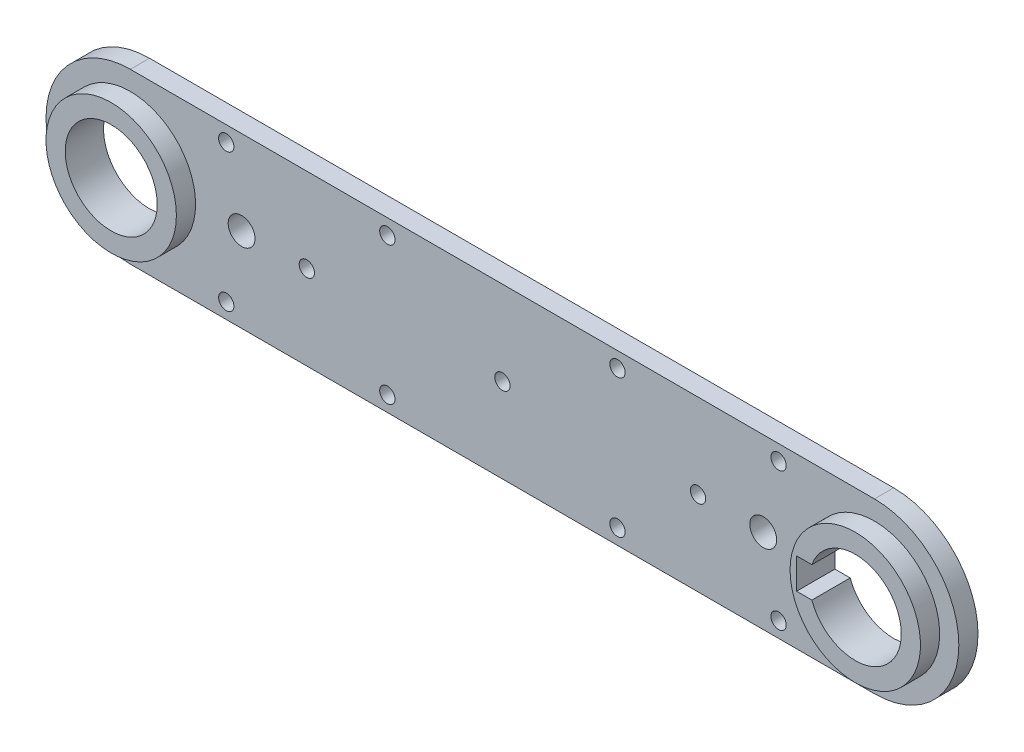
from build123d import *

# Parameters (mm, degrees)
BOSS_EXTRUDE1_DEPTH     = 5
SKETCH2_R               = 17
SKETCH2_R_2             = 12
BOSS_EXTRUDE2_DEPTH     = 5
SKETCH3_R               = 12
CUT_EXTRUDE1_DEPTH      = 6
SKETCH5_R               = 2
SKETCH5_R_2             = 3.5
CUT_EXTRUDE2_DEPTH      = 10
SKETCH9_W               = 4
SKETCH9_H               = 8
CUT_EXTRUDE4_DEPTH      = 10
M2_5_TAPPED_HOLE1_D     = 2.05
M2_5_TAPPED_HOLE1_DEPTH = 5.734117865
M2_5_TAPPED_HOLE1_TIP   = 0.615882135


with BuildPart() as part:
    # Sketch1 → Boss-Extrude1 (new body)
    with BuildSketch(Plane.XY):
        with BuildLine():
            Line((194, 22), (0, 22))
            ThreePointArc((0, 22), (-22, 0), (0, -22))
            Line((0, -22), (194, -22))
            ThreePointArc((194, -22), (216, 0), (194, 22))
        make_face()
    extrude(amount=BOSS_EXTRUDE1_DEPTH)

    # Sketch2 → Boss-Extrude2 (add)
    with BuildSketch(Plane.XY.offset(5)):
        Circle(SKETCH2_R)
        Circle(SKETCH2_R_2, mode=Mode.SUBTRACT)
        with Locations((194, 0)):
            Circle(SKETCH2_R)
        with Locations((194, 0)):
            Circle(SKETCH2_R_2, mode=Mode.SUBTRACT)
    extrude(amount=BOSS_EXTRUDE2_DEPTH)

    # Sketch3 → Cut-Extrude1 (cut)
    with BuildSketch(Plane.XY.offset(5)):
        with Locations((194, 0)):
            Circle(SKETCH3_R)
        Circle(SKETCH3_R)
    extrude(amount=-CUT_EXTRUDE1_DEPTH, mode=Mode.SUBTRACT)

    # Sketch5 → Cut-Extrude2 (cut)
    with BuildSketch(Plane(origin=(0, 0, 0), x_dir=(-1, 0, 0), z_dir=(0, 0, -1))):
        with Locations((-169, 18)):
            Circle(SKETCH5_R)
        with Locations((-67, 18)):
            Circle(SKETCH5_R)
        with Locations((-67, -18)):
            Circle(SKETCH5_R)
        with Locations((-169, -18)):
            Circle(SKETCH5_R)
        with Locations((-127, 18)):
            Circle(SKETCH5_R)
        with Locations((-127, -18)):
            Circle(SKETCH5_R)
        with Locations((-25, 18)):
            Circle(SKETCH5_R)
        with Locations((-25, -18)):
            Circle(SKETCH5_R)
        with Locations((-148, 0)):
            Circle(SKETCH5_R)
        with Locations((-97, 0)):
            Circle(SKETCH5_R)
        with Locations((-46, 0)):
            Circle(SKETCH5_R)
        with Locations((-165, 0)):
            Circle(SKETCH5_R_2)
        with Locations((-29, 0)):
            Circle(SKETCH5_R_2)
    extrude(amount=-CUT_EXTRUDE2_DEPTH, mode=Mode.SUBTRACT)

    # Sketch9 → Cut-Extrude4 (cut)
    with BuildSketch(Plane(origin=(0, 0, 0), x_dir=(-1, 0, 0), z_dir=(0, 0, -1))):
        with Locations((-180.7, 0)):
            Rectangle(SKETCH9_W, SKETCH9_H)
    extrude(amount=-CUT_EXTRUDE4_DEPTH, mode=Mode.SUBTRACT)

    # M2.5 Tapped Hole1
    with Locations(Plane(origin=(0, 0, 0), x_dir=(-1, 0, 0), z_dir=(0, 0, -1))):
        with Locations((0, 14), (14, 0), (0, -14), (-14, 0)):
            Hole(M2_5_TAPPED_HOLE1_D / 2, depth=M2_5_TAPPED_HOLE1_DEPTH)
            with Locations((0, 0, -(M2_5_TAPPED_HOLE1_DEPTH + M2_5_TAPPED_HOLE1_TIP / 2))):  # 118° drill point
                Cone(0, M2_5_TAPPED_HOLE1_D / 2, M2_5_TAPPED_HOLE1_TIP, mode=Mode.SUBTRACT)


solid = part.part
